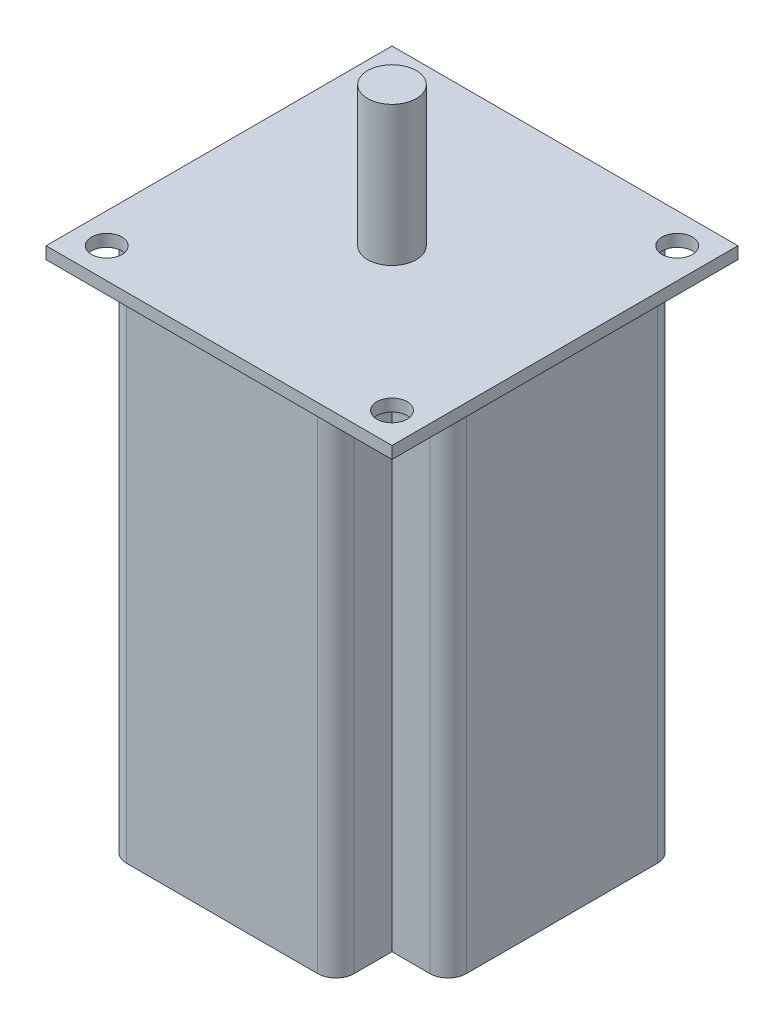
from build123d import *

# Parameters (mm, degrees)
SKETCH_1_W          = 37.5
SKETCH_1_H          = 37.5
EXTRUDE_1_DEPTH     = 82
SKETCH_2_W          = 57
SKETCH_2_H          = 57
EXTRUDE_2_DEPTH     = 2
SKETCH_3_R          = 2.5
CUT_EXTRUDE_1_DEPTH = 2
SKETCH_4_R          = 4
EXTRUDE_3_DEPTH     = 23


with BuildPart() as part:
    # 草图1 → 凸台-拉伸1 (new body)
    with BuildSketch(Plane(origin=(0, 0, 0), x_dir=(1, 0, 0), z_dir=(0, 1, 0))):
        with BuildLine():
            Line((-18.75, 18.75), (-25, 18.75))
            ThreePointArc((-25, 18.75), (-27.121320344, 17.871320344), (-28, 15.75))
            Line((-28, 15.75), (-28, -15.75))
            ThreePointArc((-28, -15.75), (-27.121320344, -17.871320344), (-25, -18.75))
            Line((-25, -18.75), (-18.75, -18.75))
            Line((-18.75, -18.75), (-18.75, 18.75))
        make_face()
        Rectangle(SKETCH_1_W, SKETCH_1_H)
        with BuildLine():
            Line((25, 18.75), (18.75, 18.75))
            Line((18.75, 18.75), (18.75, -18.75))
            Line((18.75, -18.75), (25, -18.75))
            ThreePointArc((25, -18.75), (27.121320344, -17.871320344), (28, -15.75))
            Line((28, -15.75), (28, 15.75))
            ThreePointArc((28, 15.75), (27.121320344, 17.871320344), (25, 18.75))
        make_face()
        with BuildLine():
            Line((18.75, -18.75), (-18.75, -18.75))
            Line((-18.75, -18.75), (-18.75, -25))
            ThreePointArc((-18.75, -25), (-17.871320344, -27.121320344), (-15.75, -28))
            Line((-15.75, -28), (15.75, -28))
            ThreePointArc((15.75, -28), (17.871320344, -27.121320344), (18.75, -25))
            Line((18.75, -25), (18.75, -18.75))
        make_face()
        with BuildLine():
            Line((-18.75, 25), (-18.75, 18.75))
            Line((-18.75, 18.75), (18.75, 18.75))
            Line((18.75, 18.75), (18.75, 25))
            ThreePointArc((18.75, 25), (17.871320344, 27.121320344), (15.75, 28))
            Line((15.75, 28), (-15.75, 28))
            ThreePointArc((-15.75, 28), (-17.871320344, 27.121320344), (-18.75, 25))
        make_face()
    extrude(amount=EXTRUDE_1_DEPTH)

    # 草图2 → 凸台-拉伸2 (add)
    with BuildSketch(Plane(origin=(0, 82, 0), x_dir=(1, 0, 0), z_dir=(0, 1, 0))):
        Rectangle(SKETCH_2_W, SKETCH_2_H)
    extrude(amount=-EXTRUDE_2_DEPTH)

    # 草图3 → 切除-拉伸1 (cut)
    with BuildSketch(Plane(origin=(0, 82, 0), x_dir=(1, 0, 0), z_dir=(0, 1, 0))):
        with Locations((23.5, 23.5)):
            Circle(SKETCH_3_R)
        with Locations((-23.5, 23.5)):
            Circle(SKETCH_3_R)
        with Locations((-23.5, -23.5)):
            Circle(SKETCH_3_R)
        with Locations((23.5, -23.5)):
            Circle(SKETCH_3_R)
    extrude(amount=-CUT_EXTRUDE_1_DEPTH, mode=Mode.SUBTRACT)

    # 草图4 → 凸台-拉伸3 (add)
    with BuildSketch(Plane(origin=(0, 82, 0), x_dir=(1, 0, 0), z_dir=(0, 1, 0))):
        Circle(SKETCH_4_R)
    extrude(amount=EXTRUDE_3_DEPTH)


solid = part.part
